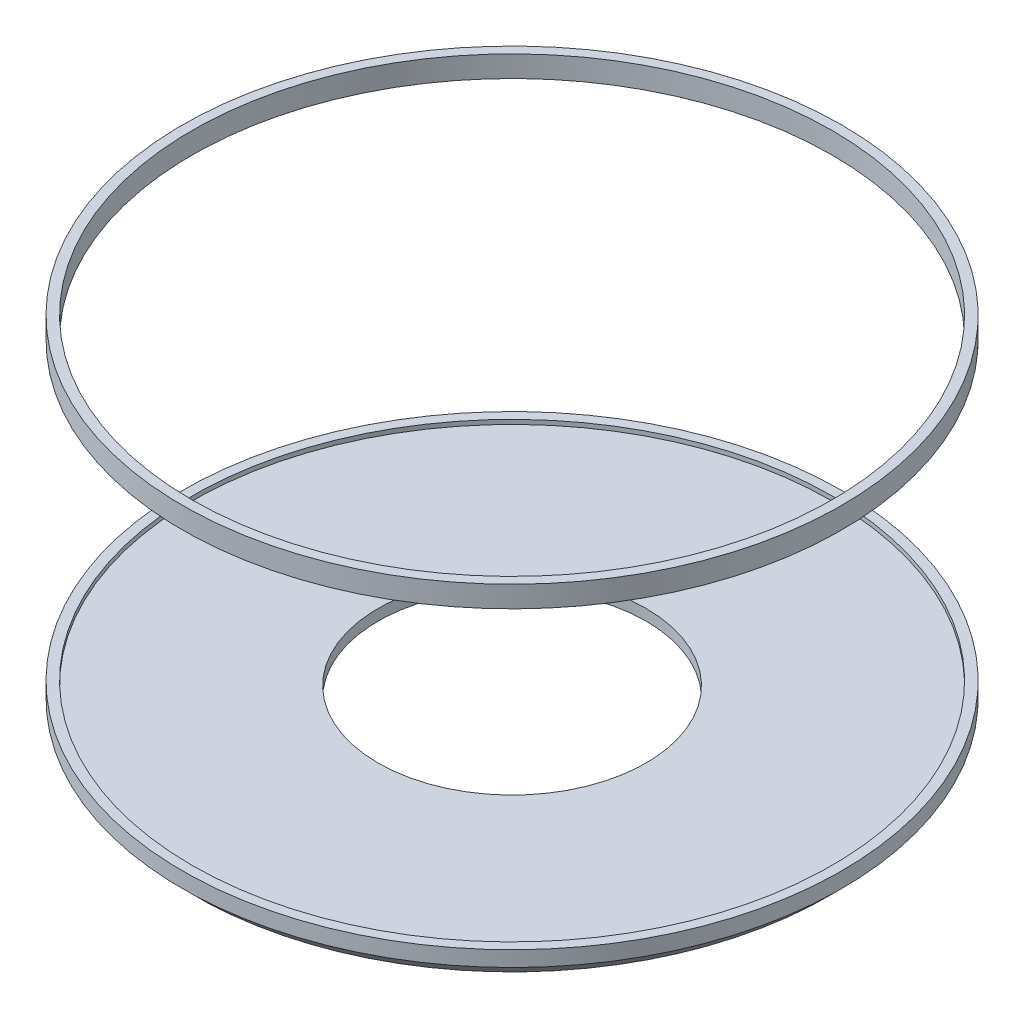
from build123d import *

# Parameters (mm, degrees)
CROQUIS2_R            = 129.627860529
CORTAR_EXTRUIR1_DEPTH = 130


with BuildPart() as part:
    # Croquis1 → Revolución1 (revolve)
    with BuildSketch(Plane(origin=(0, 0, 0), x_dir=(0, 0, -1), z_dir=(1, 0, 0))):
        Polygon((54.267285515, 67.95416726), (54.267285515, -66.513442866), (128.224471084, -66.513442866), (128.224471084, -60.270303824), (128.224471084, 59.309820895), (133.507127196, 59.309820895), (133.507127196, 67.95416726), align=None)
        Polygon((128.224471084, -60.270303824), (128.224471084, -66.513442866), (128.224471084, -71.796098978), (133.507127196, -66.513442866), (133.507127196, -60.270303824), align=None)
    revolve(axis=Axis((0, -66.513442866, 0), (0, 1, 0)))

    # Croquis2 → Cortar-Extruir1 (cut)
    with BuildSketch(Plane(origin=(0, 67.95416726, 0), x_dir=(1, 0, 0), z_dir=(0, 1, 0))):
        Circle(CROQUIS2_R)
    extrude(amount=-CORTAR_EXTRUIR1_DEPTH, mode=Mode.SUBTRACT)


solid = part.part
